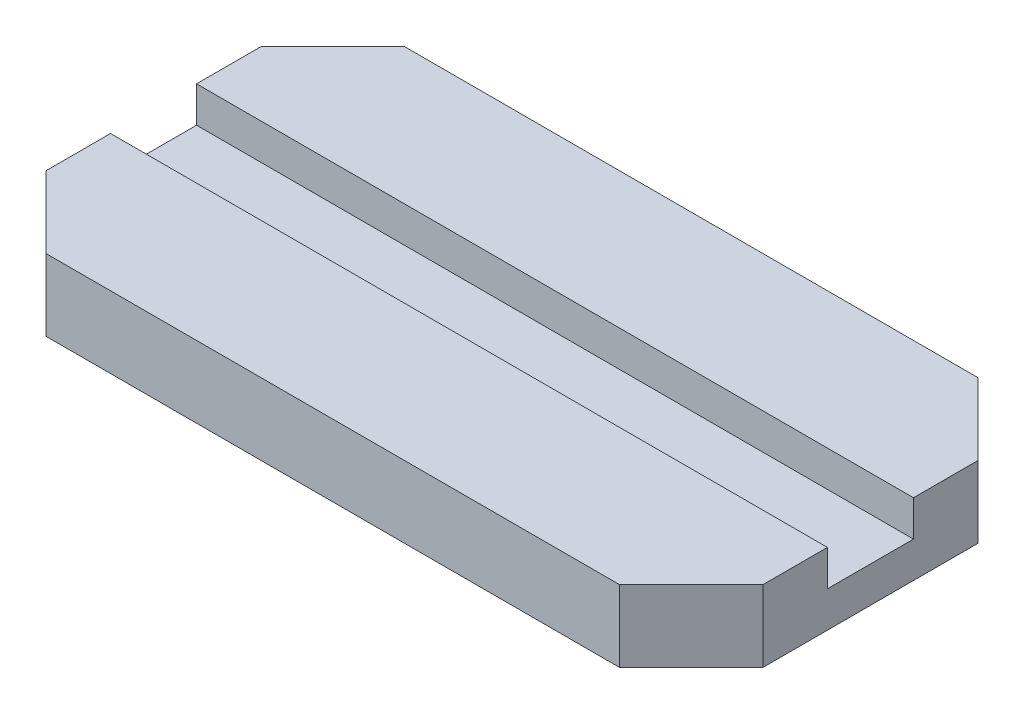
from build123d import *

# Parameters (mm, degrees)
SKETCH1_W           = 100
SKETCH1_H           = 50
BOSS_EXTRUDE1_DEPTH = 10
CHAMFER1_SIZE       = 10
SKETCH2_W           = 113.165724781
SKETCH2_H           = 12
CUT_EXTRUDE1_DEPTH  = 5


with BuildPart() as part:
    # Sketch1 → Boss-Extrude1 (new body)
    with BuildSketch(Plane(origin=(0, 0, 0), x_dir=(1, 0, 0), z_dir=(0, 1, 0))):
        Rectangle(SKETCH1_W, SKETCH1_H)
    extrude(amount=BOSS_EXTRUDE1_DEPTH)

    # Chamfer1
    chamfer1_edges = [part.edges().sort_by_distance(p)[0] for p in [
        (-50, 5, -25),
        (50, 5, -25),
        (50, 5, 25),
        (-50, 5, 25),
    ]]
    chamfer(chamfer1_edges, length=CHAMFER1_SIZE)

    # Sketch2 → Cut-Extrude1 (cut)
    with BuildSketch(Plane(origin=(0, 10, 0), x_dir=(1, 0, 0), z_dir=(0, 1, 0))):
        with Locations((-1.797960114, 0)):
            Rectangle(SKETCH2_W, SKETCH2_H)
    extrude(amount=-CUT_EXTRUDE1_DEPTH, mode=Mode.SUBTRACT)


solid = part.part
